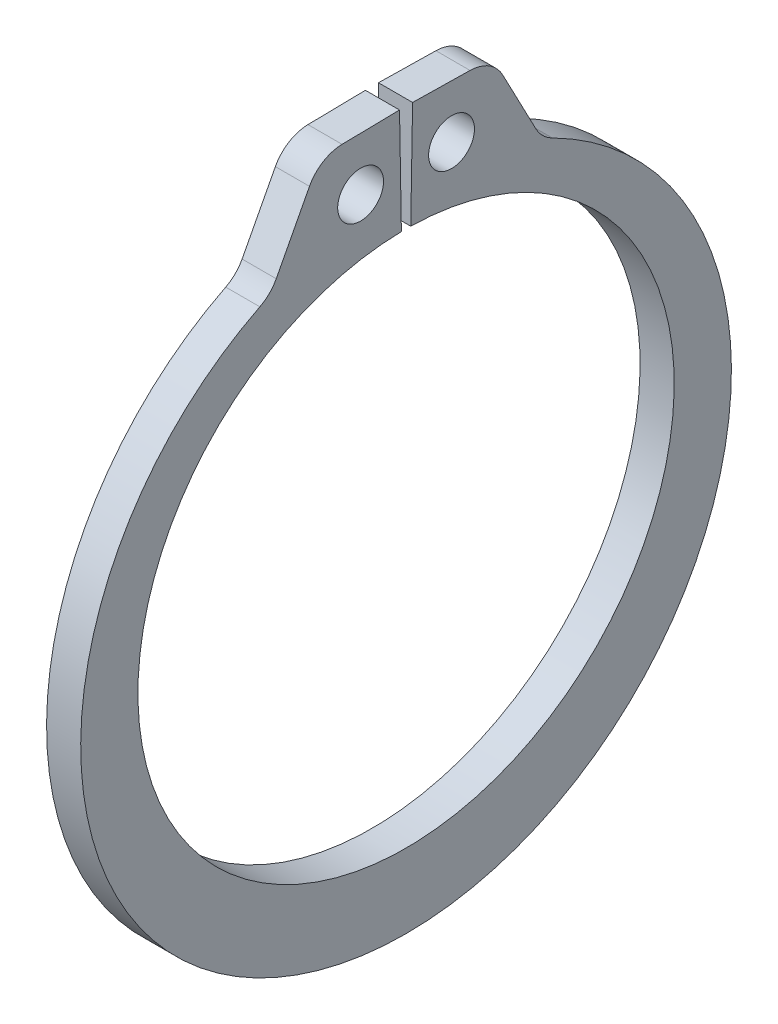
from build123d import *

# Parameters (mm, degrees)
SKETCH1_R      = 0.5969
EXTRUDE1_DEPTH = 0.4445
FILLET1_R      = 0.9779


with BuildPart() as part:
    # Sketch1 → Extrude1 (new body, symmetric)
    with BuildSketch(Plane(origin=(0, 0, 0), x_dir=(0, 0, -1), z_dir=(1, 0, 0))):
        with BuildLine():
            Line((-0.121905059, 6.983936151), (-0.170223791, 9.752114479))
            Line((-0.170223791, 9.752114479), (-2.246357538, 9.71587543))
            Line((-2.246357538, 9.71587543), (-3.532146242, 7.263959166))
            ThreePointArc((-3.532146242, 7.263959166), (0, -8.9154), (3.532146242, 7.263959166))
            Line((3.532146242, 7.263959166), (2.246357538, 9.71587543))
            Line((2.246357538, 9.71587543), (0.170223791, 9.752114479))
            Line((0.170223791, 9.752114479), (0.121905059, 6.983936151))
            ThreePointArc((0.121905059, 6.983936151), (0, -6.985), (-0.121905059, 6.983936151))
        make_face()
        with Locations((-1.184131298, 8.34990579)):
            Circle(SKETCH1_R, mode=Mode.SUBTRACT)
        with Locations((1.184131298, 8.34990579)):
            Circle(SKETCH1_R, mode=Mode.SUBTRACT)
    extrude(amount=EXTRUDE1_DEPTH, both=True)

    # Fillet1
    fillet1_edges = [part.edges().sort_by_distance(p)[0] for p in [
        (0, 9.71587543, -2.246357538),
        (0, 7.263959166, -3.532146242),
        (0, 7.263959166, 3.532146242),
        (0, 9.71587543, 2.246357538),
    ]]
    fillet(fillet1_edges, radius=FILLET1_R)


solid = part.part
